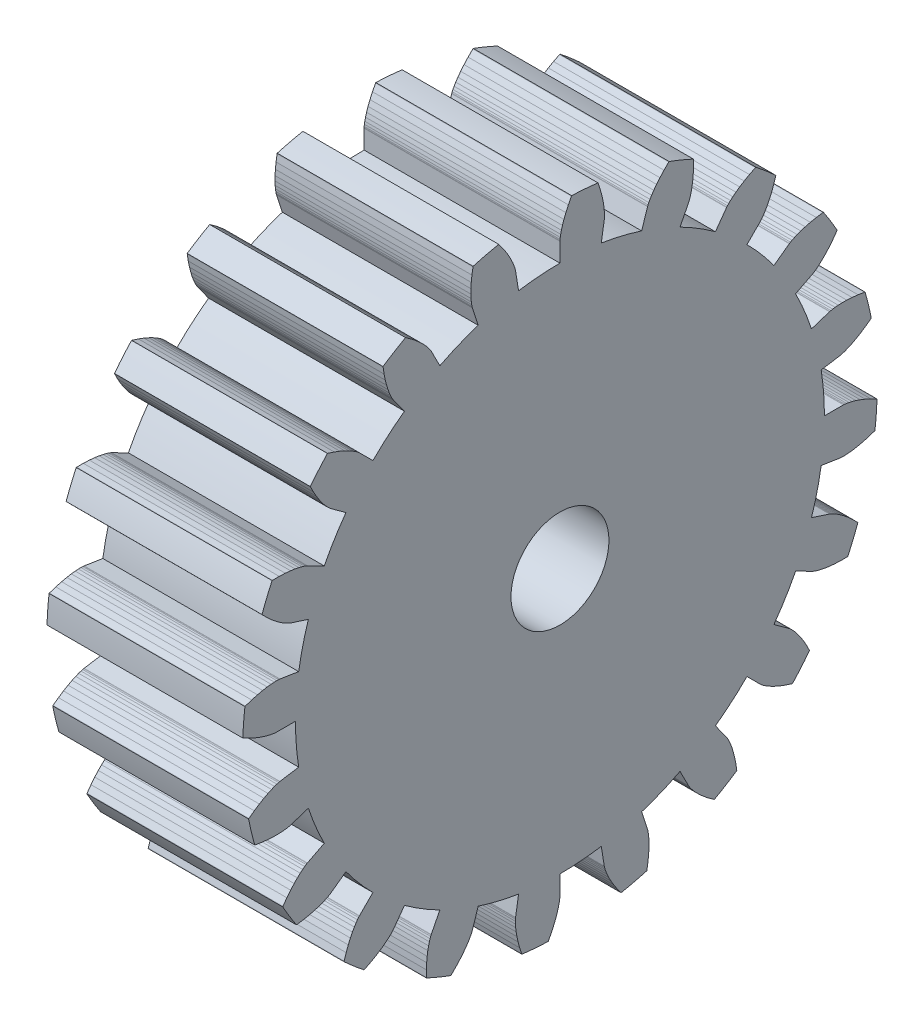
from build123d import *

# Parameters (mm, degrees)
BOSS_EXTRUDE1_DEPTH = 12.7
SKETCH2_R           = 3.175
CUT_EXTRUDE1_DEPTH  = 13.7


with BuildPart() as part:
    # Sketch1 → Boss-Extrude1 (new body)
    with BuildSketch(Plane(origin=(12.7, 0, 0), x_dir=(0, 0, -1), z_dir=(1, 0, 0))):
        with BuildLine():
            Line((2.682813922, 16.938620465), (2.875536908, 18.155425511))
            Line((2.875536908, 18.155425511), (2.87837281, 18.178225393))
            Line((2.87837281, 18.178225393), (2.883832937, 18.246933372))
            Line((2.883832937, 18.246933372), (2.887326064, 18.361754285))
            Line((2.887326064, 18.361754285), (2.884252784, 18.522548459))
            Line((2.884252784, 18.522548459), (2.870028474, 18.728831686))
            Line((2.870028474, 18.728831686), (2.840106238, 18.979776645))
            Line((2.840106238, 18.979776645), (2.789999721, 19.274215745))
            Line((2.789999721, 19.274215745), (2.715305726, 19.610645397))
            Line((2.715305726, 19.610645397), (2.611726539, 19.987231688))
            Line((2.611726539, 19.987231688), (2.475091875, 20.401817449))
            Line((2.475091875, 20.401817449), (2.46587773, 20.425692718))
            ThreePointArc((2.46587773, 20.425692718), (1.614217436, 20.510577224), (0.75976363, 20.55996681))
            Line((0.75976363, 20.55996681), (0.746928012, 20.537826895))
            Line((0.746928012, 20.537826895), (0.547120046, 20.149719743))
            Line((0.547120046, 20.149719743), (0.385905015, 19.793973209))
            Line((0.385905015, 19.793973209), (0.259501435, 19.47337028))
            Line((0.259501435, 19.47337028), (0.163951389, 19.190394599))
            Line((0.163951389, 19.190394599), (0.095141104, 18.947220058))
            Line((0.095141104, 18.947220058), (0.048822113, 18.745701692))
            Line((0.048822113, 18.745701692), (0.020632919, 18.587367929))
            Line((0.020632919, 18.587367929), (0.006121093, 18.473414206))
            Line((0.006121093, 18.473414206), (0.000765701, 18.404697984))
            Line((0.000765701, 18.404697984), (0, 18.381735174))
            Line((0, 18.381735174), (0, 17.1497625))
            ThreePointArc((0, 17.1497625), (-1.345554858, 17.096895506), (-2.682813922, 16.938620465))
            Line((-2.682813922, 16.938620465), (-2.875536908, 18.155425511))
            Line((-2.875536908, 18.155425511), (-2.879885357, 18.177985829))
            Line((-2.879885357, 18.177985829), (-2.895924401, 18.245018272))
            Line((-2.895924401, 18.245018272), (-2.928083852, 18.355298886))
            Line((-2.928083852, 18.355298886), (-2.980694848, 18.507273536))
            Line((-2.980694848, 18.507273536), (-3.057967993, 18.69906499))
            Line((-3.057967993, 18.69906499), (-3.163971988, 18.928481349))
            Line((-3.163971988, 18.928481349), (-3.302612804, 19.193025809))
            Line((-3.302612804, 19.193025809), (-3.477613494, 19.489907708))
            Line((-3.477613494, 19.489907708), (-3.692494719, 19.816054825))
            Line((-3.692494719, 19.816054825), (-3.950556052, 20.168126881))
            Line((-3.950556052, 20.168126881), (-3.966697089, 20.187986284))
            ThreePointArc((-3.966697089, 20.187986284), (-4.802904916, 20.005538742), (-5.630800996, 19.788470283))
            Line((-5.630800996, 19.788470283), (-5.636166785, 19.763447548))
            Line((-5.636166785, 19.763447548), (-5.706263748, 19.332591656))
            Line((-5.706263748, 19.332591656), (-5.749656629, 18.944438412))
            Line((-5.749656629, 18.944438412), (-5.770801824, 18.600466052))
            Line((-5.770801824, 18.600466052), (-5.774231023, 18.301813599))
            Line((-5.774231023, 18.301813599), (-5.764528427, 18.04927732))
            Line((-5.764528427, 18.04927732), (-5.746307806, 17.843308609))
            Line((-5.746307806, 17.843308609), (-5.724189498, 17.684013312))
            Line((-5.724189498, 17.684013312), (-5.702777429, 17.57115248))
            Line((-5.702777429, 17.57115248), (-5.686636229, 17.504144563))
            Line((-5.686636229, 17.504144563), (-5.680268555, 17.482069018))
            Line((-5.680268555, 17.482069018), (-5.299568062, 16.310393379))
            ThreePointArc((-5.299568062, 16.310393379), (-6.562929978, 15.844314561), (-7.785829248, 15.280550276))
            Line((-7.785829248, 15.280550276), (-8.345133138, 16.378245966))
            Line((-8.345133138, 16.378245966), (-8.35624028, 16.398358359))
            Line((-8.35624028, 16.398358359), (-8.392208481, 16.457153664))
            Line((-8.392208481, 16.457153664), (-8.456872521, 16.552098943))
            Line((-8.456872521, 16.552098943), (-8.553871301, 16.680377733))
            Line((-8.553871301, 16.680377733), (-8.686629248, 16.838903529))
            Line((-8.686629248, 16.838903529), (-8.858338591, 17.024334417))
            Line((-8.858338591, 17.024334417), (-9.071942576, 17.233088781))
            Line((-9.071942576, 17.233088781), (-9.330119675, 17.461362059))
            Line((-9.330119675, 17.461362059), (-9.635268866, 17.705144449))
            Line((-9.635268866, 17.705144449), (-9.989496027, 17.960239535))
            Line((-9.989496027, 17.960239535), (-10.010983958, 17.974139094))
            ThreePointArc((-10.010983958, 17.974139094), (-10.74988547, 17.542218741), (-11.47018359, 17.07994041))
            Line((-11.47018359, 17.07994041), (-11.467554308, 17.054484255))
            Line((-11.467554308, 17.054484255), (-11.401078688, 16.623054798))
            Line((-11.401078688, 16.623054798), (-11.322401821, 16.240489989))
            Line((-11.322401821, 16.240489989), (-11.236218792, 15.90681861))
            Line((-11.236218792, 15.90681861), (-11.147191471, 15.621723568))
            Line((-11.147191471, 15.621723568), (-11.059925752, 15.384545561))
            Line((-11.059925752, 15.384545561), (-10.978949079, 15.194288158))
            Line((-10.978949079, 15.194288158), (-10.908688365, 15.049624261))
            Line((-10.908688365, 15.049624261), (-10.853448362, 14.948903925))
            Line((-10.853448362, 14.948903925), (-10.817390583, 14.890163513))
            Line((-10.817390583, 14.890163513), (-10.804512847, 14.871136142))
            Line((-10.804512847, 14.871136142), (-10.080377478, 13.874449312))
            ThreePointArc((-10.080377478, 13.874449312), (-11.137879785, 13.040781714), (-12.126713359, 12.126713359))
            Line((-12.126713359, 12.126713359), (-12.997849592, 12.997849592))
            Line((-12.997849592, 12.997849592), (-13.014628182, 13.013545318))
            Line((-13.014628182, 13.013545318), (-13.067004723, 13.05834819))
            Line((-13.067004723, 13.05834819), (-13.157843584, 13.12866423))
            Line((-13.157843584, 13.12866423), (-13.289735232, 13.220690337))
            Line((-13.289735232, 13.220690337), (-13.464982708, 13.330432868))
            Line((-13.464982708, 13.330432868), (-13.685589294, 13.453727016))
            Line((-13.685589294, 13.453727016), (-13.953247401, 13.586256953))
            Line((-13.953247401, 13.586256953), (-14.269328736, 13.72357663))
            Line((-14.269328736, 13.72357663), (-14.634875764, 13.861131175))
            Line((-14.634875764, 13.861131175), (-15.05059453, 13.994278806))
            Line((-15.05059453, 13.994278806), (-15.075325967, 14.000857937))
            ThreePointArc((-15.075325967, 14.000857937), (-15.644592336, 13.361744146), (-16.186784696, 12.699506967))
            Line((-16.186784696, 12.699506967), (-16.176417716, 12.676109218))
            Line((-16.176417716, 12.676109218), (-15.97987661, 12.286337518))
            Line((-15.97987661, 12.286337518), (-15.786831436, 11.946809252))
            Line((-15.786831436, 11.946809252), (-15.601756378, 11.656100933))
            Line((-15.601756378, 11.656100933), (-15.428987151, 11.412470391))
            Line((-15.428987151, 11.412470391), (-15.272700485, 11.213867292))
            Line((-15.272700485, 11.213867292), (-15.136894322, 11.057944918))
            Line((-15.136894322, 11.057944918), (-15.025368809, 10.94207313))
            Line((-15.025368809, 10.94207313), (-14.941708149, 10.863352498))
            Line((-14.941708149, 10.863352498), (-14.889263378, 10.818629513))
            Line((-14.889263378, 10.818629513), (-14.871136142, 10.804512847))
            Line((-14.871136142, 10.804512847), (-13.874449312, 10.080377478))
            ThreePointArc((-13.874449312, 10.080377478), (-14.622576317, 8.960726291), (-15.280550276, 7.785829248))
            Line((-15.280550276, 7.785829248), (-16.378245966, 8.345133138))
            Line((-16.378245966, 8.345133138), (-16.3990536, 8.354875791))
            Line((-16.3990536, 8.354875791), (-16.462711499, 8.381300614))
            Line((-16.462711499, 8.381300614), (-16.570833241, 8.420104389))
            Line((-16.570833241, 8.420104389), (-16.724707284, 8.466869658))
            Line((-16.724707284, 8.466869658), (-16.925289844, 8.517086558))
            Line((-16.925289844, 8.517086558), (-17.173199163, 8.566175077))
            Line((-17.173199163, 8.566175077), (-17.468711153, 8.609507634))
            Line((-17.468711153, 8.609507634), (-17.81175648, 8.642431903))
            Line((-17.81175648, 8.642431903), (-18.201919055, 8.660293806))
            Line((-18.201919055, 8.660293806), (-18.638435977, 8.658460564))
            Line((-18.638435977, 8.658460564), (-18.663990035, 8.657075255))
            ThreePointArc((-18.663990035, 8.657075255), (-19.007897502, 7.873328937), (-19.318910536, 7.0759573))
            Line((-19.318910536, 7.0759573), (-19.30182065, 7.056908291))
            Line((-19.30182065, 7.056908291), (-18.994452871, 6.746947917))
            Line((-18.994452871, 6.746947917), (-18.705935996, 6.483691587))
            Line((-18.705935996, 6.483691587), (-18.440085345, 6.264402885))
            Line((-18.440085345, 6.264402885), (-18.200486068, 6.086085097))
            Line((-18.200486068, 6.086085097), (-17.990476884, 5.945497561))
            Line((-17.990476884, 5.945497561), (-17.813134884, 5.839172983))
            Line((-17.813134884, 5.839172983), (-17.671261467, 5.763435643))
            Line((-17.671261467, 5.763435643), (-17.567369437, 5.714420439))
            Line((-17.567369437, 5.714420439), (-17.503671334, 5.688092678))
            Line((-17.503671334, 5.688092678), (-17.482069018, 5.680268555))
            Line((-17.482069018, 5.680268555), (-16.310393379, 5.299568062))
            ThreePointArc((-16.310393379, 5.299568062), (-16.675913197, 4.003532547), (-16.938620465, 2.682813922))
            Line((-16.938620465, 2.682813922), (-18.155425511, 2.875536908))
            Line((-18.155425511, 2.875536908), (-18.178225393, 2.87837281))
            Line((-18.178225393, 2.87837281), (-18.246933372, 2.883832937))
            Line((-18.246933372, 2.883832937), (-18.361754285, 2.887326064))
            Line((-18.361754285, 2.887326064), (-18.522548459, 2.884252784))
            Line((-18.522548459, 2.884252784), (-18.728831686, 2.870028474))
            Line((-18.728831686, 2.870028474), (-18.979776645, 2.840106238))
            Line((-18.979776645, 2.840106238), (-19.274215745, 2.789999721))
            Line((-19.274215745, 2.789999721), (-19.610645397, 2.715305726))
            Line((-19.610645397, 2.715305726), (-19.987231688, 2.611726539))
            Line((-19.987231688, 2.611726539), (-20.401817449, 2.475091875))
            Line((-20.401817449, 2.475091875), (-20.425692718, 2.46587773))
            ThreePointArc((-20.425692718, 2.46587773), (-20.510577224, 1.614217436), (-20.55996681, 0.75976363))
            Line((-20.55996681, 0.75976363), (-20.537826895, 0.746928012))
            Line((-20.537826895, 0.746928012), (-20.149719743, 0.547120046))
            Line((-20.149719743, 0.547120046), (-19.793973209, 0.385905015))
            Line((-19.793973209, 0.385905015), (-19.47337028, 0.259501435))
            Line((-19.47337028, 0.259501435), (-19.190394599, 0.163951389))
            Line((-19.190394599, 0.163951389), (-18.947220058, 0.095141104))
            Line((-18.947220058, 0.095141104), (-18.745701692, 0.048822113))
            Line((-18.745701692, 0.048822113), (-18.587367929, 0.020632919))
            Line((-18.587367929, 0.020632919), (-18.473414206, 0.006121093))
            Line((-18.473414206, 0.006121093), (-18.404697984, 0.000765701))
            Line((-18.404697984, 0.000765701), (-18.381735174, 0))
            Line((-18.381735174, 0), (-17.1497625, 0))
            ThreePointArc((-17.1497625, 0), (-17.096895506, -1.345554858), (-16.938620465, -2.682813922))
            Line((-16.938620465, -2.682813922), (-18.155425511, -2.875536908))
            Line((-18.155425511, -2.875536908), (-18.177985829, -2.879885357))
            Line((-18.177985829, -2.879885357), (-18.245018272, -2.895924401))
            Line((-18.245018272, -2.895924401), (-18.355298886, -2.928083852))
            Line((-18.355298886, -2.928083852), (-18.507273536, -2.980694848))
            Line((-18.507273536, -2.980694848), (-18.69906499, -3.057967993))
            Line((-18.69906499, -3.057967993), (-18.928481349, -3.163971988))
            Line((-18.928481349, -3.163971988), (-19.193025809, -3.302612804))
            Line((-19.193025809, -3.302612804), (-19.489907708, -3.477613494))
            Line((-19.489907708, -3.477613494), (-19.816054825, -3.692494719))
            Line((-19.816054825, -3.692494719), (-20.168126881, -3.950556052))
            Line((-20.168126881, -3.950556052), (-20.187986284, -3.966697089))
            ThreePointArc((-20.187986284, -3.966697089), (-20.005538742, -4.802904916), (-19.788470283, -5.630800996))
            Line((-19.788470283, -5.630800996), (-19.763447548, -5.636166785))
            Line((-19.763447548, -5.636166785), (-19.332591656, -5.706263748))
            Line((-19.332591656, -5.706263748), (-18.944438412, -5.749656629))
            Line((-18.944438412, -5.749656629), (-18.600466052, -5.770801824))
            Line((-18.600466052, -5.770801824), (-18.301813599, -5.774231023))
            Line((-18.301813599, -5.774231023), (-18.04927732, -5.764528427))
            Line((-18.04927732, -5.764528427), (-17.843308609, -5.746307806))
            Line((-17.843308609, -5.746307806), (-17.684013312, -5.724189498))
            Line((-17.684013312, -5.724189498), (-17.57115248, -5.702777429))
            Line((-17.57115248, -5.702777429), (-17.504144563, -5.686636229))
            Line((-17.504144563, -5.686636229), (-17.482069018, -5.680268555))
            Line((-17.482069018, -5.680268555), (-16.310393379, -5.299568062))
            ThreePointArc((-16.310393379, -5.299568062), (-15.844314561, -6.562929978), (-15.280550276, -7.785829248))
            Line((-15.280550276, -7.785829248), (-16.378245966, -8.345133138))
            Line((-16.378245966, -8.345133138), (-16.398358359, -8.35624028))
            Line((-16.398358359, -8.35624028), (-16.457153664, -8.392208481))
            Line((-16.457153664, -8.392208481), (-16.552098943, -8.456872521))
            Line((-16.552098943, -8.456872521), (-16.680377733, -8.553871301))
            Line((-16.680377733, -8.553871301), (-16.838903529, -8.686629248))
            Line((-16.838903529, -8.686629248), (-17.024334417, -8.858338591))
            Line((-17.024334417, -8.858338591), (-17.233088781, -9.071942576))
            Line((-17.233088781, -9.071942576), (-17.461362059, -9.330119675))
            Line((-17.461362059, -9.330119675), (-17.705144449, -9.635268866))
            Line((-17.705144449, -9.635268866), (-17.960239535, -9.989496027))
            Line((-17.960239535, -9.989496027), (-17.974139094, -10.010983958))
            ThreePointArc((-17.974139094, -10.010983958), (-17.542218741, -10.74988547), (-17.07994041, -11.47018359))
            Line((-17.07994041, -11.47018359), (-17.054484255, -11.467554308))
            Line((-17.054484255, -11.467554308), (-16.623054798, -11.401078688))
            Line((-16.623054798, -11.401078688), (-16.240489989, -11.322401821))
            Line((-16.240489989, -11.322401821), (-15.90681861, -11.236218792))
            Line((-15.90681861, -11.236218792), (-15.621723568, -11.147191471))
            Line((-15.621723568, -11.147191471), (-15.384545561, -11.059925752))
            Line((-15.384545561, -11.059925752), (-15.194288158, -10.978949079))
            Line((-15.194288158, -10.978949079), (-15.049624261, -10.908688365))
            Line((-15.049624261, -10.908688365), (-14.948903925, -10.853448362))
            Line((-14.948903925, -10.853448362), (-14.890163513, -10.817390583))
            Line((-14.890163513, -10.817390583), (-14.871136142, -10.804512847))
            Line((-14.871136142, -10.804512847), (-13.874449312, -10.080377478))
            ThreePointArc((-13.874449312, -10.080377478), (-13.040781714, -11.137879785), (-12.126713359, -12.126713359))
            Line((-12.126713359, -12.126713359), (-12.997849592, -12.997849592))
            Line((-12.997849592, -12.997849592), (-13.013545318, -13.014628182))
            Line((-13.013545318, -13.014628182), (-13.05834819, -13.067004723))
            Line((-13.05834819, -13.067004723), (-13.12866423, -13.157843584))
            Line((-13.12866423, -13.157843584), (-13.220690337, -13.289735232))
            Line((-13.220690337, -13.289735232), (-13.330432868, -13.464982708))
            Line((-13.330432868, -13.464982708), (-13.453727016, -13.685589294))
            Line((-13.453727016, -13.685589294), (-13.586256953, -13.953247401))
            Line((-13.586256953, -13.953247401), (-13.72357663, -14.269328736))
            Line((-13.72357663, -14.269328736), (-13.861131175, -14.634875764))
            Line((-13.861131175, -14.634875764), (-13.994278806, -15.05059453))
            Line((-13.994278806, -15.05059453), (-14.000857937, -15.075325967))
            ThreePointArc((-14.000857937, -15.075325967), (-13.361744146, -15.644592336), (-12.699506967, -16.186784696))
            Line((-12.699506967, -16.186784696), (-12.676109218, -16.176417716))
            Line((-12.676109218, -16.176417716), (-12.286337518, -15.97987661))
            Line((-12.286337518, -15.97987661), (-11.946809252, -15.786831436))
            Line((-11.946809252, -15.786831436), (-11.656100933, -15.601756378))
            Line((-11.656100933, -15.601756378), (-11.412470391, -15.428987151))
            Line((-11.412470391, -15.428987151), (-11.213867292, -15.272700485))
            Line((-11.213867292, -15.272700485), (-11.057944918, -15.136894322))
            Line((-11.057944918, -15.136894322), (-10.94207313, -15.025368809))
            Line((-10.94207313, -15.025368809), (-10.863352498, -14.941708149))
            Line((-10.863352498, -14.941708149), (-10.818629513, -14.889263378))
            Line((-10.818629513, -14.889263378), (-10.804512847, -14.871136142))
            Line((-10.804512847, -14.871136142), (-10.080377478, -13.874449312))
            ThreePointArc((-10.080377478, -13.874449312), (-8.960726291, -14.622576317), (-7.785829248, -15.280550276))
            Line((-7.785829248, -15.280550276), (-8.345133138, -16.378245966))
            Line((-8.345133138, -16.378245966), (-8.354875791, -16.3990536))
            Line((-8.354875791, -16.3990536), (-8.381300614, -16.462711499))
            Line((-8.381300614, -16.462711499), (-8.420104389, -16.570833241))
            Line((-8.420104389, -16.570833241), (-8.466869658, -16.724707284))
            Line((-8.466869658, -16.724707284), (-8.517086558, -16.925289844))
            Line((-8.517086558, -16.925289844), (-8.566175077, -17.173199163))
            Line((-8.566175077, -17.173199163), (-8.609507634, -17.468711153))
            Line((-8.609507634, -17.468711153), (-8.642431903, -17.81175648))
            Line((-8.642431903, -17.81175648), (-8.660293806, -18.201919055))
            Line((-8.660293806, -18.201919055), (-8.658460564, -18.638435977))
            Line((-8.658460564, -18.638435977), (-8.657075255, -18.663990035))
            ThreePointArc((-8.657075255, -18.663990035), (-7.873328937, -19.007897502), (-7.0759573, -19.318910536))
            Line((-7.0759573, -19.318910536), (-7.056908291, -19.30182065))
            Line((-7.056908291, -19.30182065), (-6.746947917, -18.994452871))
            Line((-6.746947917, -18.994452871), (-6.483691587, -18.705935996))
            Line((-6.483691587, -18.705935996), (-6.264402885, -18.440085345))
            Line((-6.264402885, -18.440085345), (-6.086085097, -18.200486068))
            Line((-6.086085097, -18.200486068), (-5.945497561, -17.990476884))
            Line((-5.945497561, -17.990476884), (-5.839172983, -17.813134884))
            Line((-5.839172983, -17.813134884), (-5.763435643, -17.671261467))
            Line((-5.763435643, -17.671261467), (-5.714420439, -17.567369437))
            Line((-5.714420439, -17.567369437), (-5.688092678, -17.503671334))
            Line((-5.688092678, -17.503671334), (-5.680268555, -17.482069018))
            Line((-5.680268555, -17.482069018), (-5.299568062, -16.310393379))
            ThreePointArc((-5.299568062, -16.310393379), (-4.003532547, -16.675913197), (-2.682813922, -16.938620465))
            Line((-2.682813922, -16.938620465), (-2.875536908, -18.155425511))
            Line((-2.875536908, -18.155425511), (-2.87837281, -18.178225393))
            Line((-2.87837281, -18.178225393), (-2.883832937, -18.246933372))
            Line((-2.883832937, -18.246933372), (-2.887326064, -18.361754285))
            Line((-2.887326064, -18.361754285), (-2.884252784, -18.522548459))
            Line((-2.884252784, -18.522548459), (-2.870028474, -18.728831686))
            Line((-2.870028474, -18.728831686), (-2.840106238, -18.979776645))
            Line((-2.840106238, -18.979776645), (-2.789999721, -19.274215745))
            Line((-2.789999721, -19.274215745), (-2.715305726, -19.610645397))
            Line((-2.715305726, -19.610645397), (-2.611726539, -19.987231688))
            Line((-2.611726539, -19.987231688), (-2.475091875, -20.401817449))
            Line((-2.475091875, -20.401817449), (-2.46587773, -20.425692718))
            ThreePointArc((-2.46587773, -20.425692718), (-1.614217436, -20.510577224), (-0.75976363, -20.55996681))
            Line((-0.75976363, -20.55996681), (-0.746928012, -20.537826895))
            Line((-0.746928012, -20.537826895), (-0.547120046, -20.149719743))
            Line((-0.547120046, -20.149719743), (-0.385905015, -19.793973209))
            Line((-0.385905015, -19.793973209), (-0.259501435, -19.47337028))
            Line((-0.259501435, -19.47337028), (-0.163951389, -19.190394599))
            Line((-0.163951389, -19.190394599), (-0.095141104, -18.947220058))
            Line((-0.095141104, -18.947220058), (-0.048822113, -18.745701692))
            Line((-0.048822113, -18.745701692), (-0.020632919, -18.587367929))
            Line((-0.020632919, -18.587367929), (-0.006121093, -18.473414206))
            Line((-0.006121093, -18.473414206), (-0.000765701, -18.404697984))
            Line((-0.000765701, -18.404697984), (0, -18.381735174))
            Line((0, -18.381735174), (0, -17.1497625))
            ThreePointArc((0, -17.1497625), (1.345554858, -17.096895506), (2.682813922, -16.938620465))
            Line((2.682813922, -16.938620465), (2.875536908, -18.155425511))
            Line((2.875536908, -18.155425511), (2.879885357, -18.177985829))
            Line((2.879885357, -18.177985829), (2.895924401, -18.245018272))
            Line((2.895924401, -18.245018272), (2.928083852, -18.355298886))
            Line((2.928083852, -18.355298886), (2.980694848, -18.507273536))
            Line((2.980694848, -18.507273536), (3.057967993, -18.69906499))
            Line((3.057967993, -18.69906499), (3.163971988, -18.928481349))
            Line((3.163971988, -18.928481349), (3.302612804, -19.193025809))
            Line((3.302612804, -19.193025809), (3.477613494, -19.489907708))
            Line((3.477613494, -19.489907708), (3.692494719, -19.816054825))
            Line((3.692494719, -19.816054825), (3.950556052, -20.168126881))
            Line((3.950556052, -20.168126881), (3.966697089, -20.187986284))
            ThreePointArc((3.966697089, -20.187986284), (4.802904916, -20.005538742), (5.630800996, -19.788470283))
            Line((5.630800996, -19.788470283), (5.636166785, -19.763447548))
            Line((5.636166785, -19.763447548), (5.706263748, -19.332591656))
            Line((5.706263748, -19.332591656), (5.749656629, -18.944438412))
            Line((5.749656629, -18.944438412), (5.770801824, -18.600466052))
            Line((5.770801824, -18.600466052), (5.774231023, -18.301813599))
            Line((5.774231023, -18.301813599), (5.764528427, -18.04927732))
            Line((5.764528427, -18.04927732), (5.746307806, -17.843308609))
            Line((5.746307806, -17.843308609), (5.724189498, -17.684013312))
            Line((5.724189498, -17.684013312), (5.702777429, -17.57115248))
            Line((5.702777429, -17.57115248), (5.686636229, -17.504144563))
            Line((5.686636229, -17.504144563), (5.680268555, -17.482069018))
            Line((5.680268555, -17.482069018), (5.299568062, -16.310393379))
            ThreePointArc((5.299568062, -16.310393379), (6.562929978, -15.844314561), (7.785829248, -15.280550276))
            Line((7.785829248, -15.280550276), (8.345133138, -16.378245966))
            Line((8.345133138, -16.378245966), (8.35624028, -16.398358359))
            Line((8.35624028, -16.398358359), (8.392208481, -16.457153664))
            Line((8.392208481, -16.457153664), (8.456872521, -16.552098943))
            Line((8.456872521, -16.552098943), (8.553871301, -16.680377733))
            Line((8.553871301, -16.680377733), (8.686629248, -16.838903529))
            Line((8.686629248, -16.838903529), (8.858338591, -17.024334417))
            Line((8.858338591, -17.024334417), (9.071942576, -17.233088781))
            Line((9.071942576, -17.233088781), (9.330119675, -17.461362059))
            Line((9.330119675, -17.461362059), (9.635268866, -17.705144449))
            Line((9.635268866, -17.705144449), (9.989496027, -17.960239535))
            Line((9.989496027, -17.960239535), (10.010983958, -17.974139094))
            ThreePointArc((10.010983958, -17.974139094), (10.74988547, -17.542218741), (11.47018359, -17.07994041))
            Line((11.47018359, -17.07994041), (11.467554308, -17.054484255))
            Line((11.467554308, -17.054484255), (11.401078688, -16.623054798))
            Line((11.401078688, -16.623054798), (11.322401821, -16.240489989))
            Line((11.322401821, -16.240489989), (11.236218792, -15.90681861))
            Line((11.236218792, -15.90681861), (11.147191471, -15.621723568))
            Line((11.147191471, -15.621723568), (11.059925752, -15.384545561))
            Line((11.059925752, -15.384545561), (10.978949079, -15.194288158))
            Line((10.978949079, -15.194288158), (10.908688365, -15.049624261))
            Line((10.908688365, -15.049624261), (10.853448362, -14.948903925))
            Line((10.853448362, -14.948903925), (10.817390583, -14.890163513))
            Line((10.817390583, -14.890163513), (10.804512847, -14.871136142))
            Line((10.804512847, -14.871136142), (10.080377478, -13.874449312))
            ThreePointArc((10.080377478, -13.874449312), (11.137879785, -13.040781714), (12.126713359, -12.126713359))
            Line((12.126713359, -12.126713359), (12.997849592, -12.997849592))
            Line((12.997849592, -12.997849592), (13.014628182, -13.013545318))
            Line((13.014628182, -13.013545318), (13.067004723, -13.05834819))
            Line((13.067004723, -13.05834819), (13.157843584, -13.12866423))
            Line((13.157843584, -13.12866423), (13.289735232, -13.220690337))
            Line((13.289735232, -13.220690337), (13.464982708, -13.330432868))
            Line((13.464982708, -13.330432868), (13.685589294, -13.453727016))
            Line((13.685589294, -13.453727016), (13.953247401, -13.586256953))
            Line((13.953247401, -13.586256953), (14.269328736, -13.72357663))
            Line((14.269328736, -13.72357663), (14.634875764, -13.861131175))
            Line((14.634875764, -13.861131175), (15.05059453, -13.994278806))
            Line((15.05059453, -13.994278806), (15.075325967, -14.000857937))
            ThreePointArc((15.075325967, -14.000857937), (15.644592336, -13.361744146), (16.186784696, -12.699506967))
            Line((16.186784696, -12.699506967), (16.176417716, -12.676109218))
            Line((16.176417716, -12.676109218), (15.97987661, -12.286337518))
            Line((15.97987661, -12.286337518), (15.786831436, -11.946809252))
            Line((15.786831436, -11.946809252), (15.601756378, -11.656100933))
            Line((15.601756378, -11.656100933), (15.428987151, -11.412470391))
            Line((15.428987151, -11.412470391), (15.272700485, -11.213867292))
            Line((15.272700485, -11.213867292), (15.136894322, -11.057944918))
            Line((15.136894322, -11.057944918), (15.025368809, -10.94207313))
            Line((15.025368809, -10.94207313), (14.941708149, -10.863352498))
            Line((14.941708149, -10.863352498), (14.889263378, -10.818629513))
            Line((14.889263378, -10.818629513), (14.871136142, -10.804512847))
            Line((14.871136142, -10.804512847), (13.874449312, -10.080377478))
            ThreePointArc((13.874449312, -10.080377478), (14.622576317, -8.960726291), (15.280550276, -7.785829248))
            Line((15.280550276, -7.785829248), (16.378245966, -8.345133138))
            Line((16.378245966, -8.345133138), (16.3990536, -8.354875791))
            Line((16.3990536, -8.354875791), (16.462711499, -8.381300614))
            Line((16.462711499, -8.381300614), (16.570833241, -8.420104389))
            Line((16.570833241, -8.420104389), (16.724707284, -8.466869658))
            Line((16.724707284, -8.466869658), (16.925289844, -8.517086558))
            Line((16.925289844, -8.517086558), (17.173199163, -8.566175077))
            Line((17.173199163, -8.566175077), (17.468711153, -8.609507634))
            Line((17.468711153, -8.609507634), (17.81175648, -8.642431903))
            Line((17.81175648, -8.642431903), (18.201919055, -8.660293806))
            Line((18.201919055, -8.660293806), (18.638435977, -8.658460564))
            Line((18.638435977, -8.658460564), (18.663990035, -8.657075255))
            ThreePointArc((18.663990035, -8.657075255), (19.007897502, -7.873328937), (19.318910536, -7.0759573))
            Line((19.318910536, -7.0759573), (19.30182065, -7.056908291))
            Line((19.30182065, -7.056908291), (18.994452871, -6.746947917))
            Line((18.994452871, -6.746947917), (18.705935996, -6.483691587))
            Line((18.705935996, -6.483691587), (18.440085345, -6.264402885))
            Line((18.440085345, -6.264402885), (18.200486068, -6.086085097))
            Line((18.200486068, -6.086085097), (17.990476884, -5.945497561))
            Line((17.990476884, -5.945497561), (17.813134884, -5.839172983))
            Line((17.813134884, -5.839172983), (17.671261467, -5.763435643))
            Line((17.671261467, -5.763435643), (17.567369437, -5.714420439))
            Line((17.567369437, -5.714420439), (17.503671334, -5.688092678))
            Line((17.503671334, -5.688092678), (17.482069018, -5.680268555))
            Line((17.482069018, -5.680268555), (16.310393379, -5.299568062))
            ThreePointArc((16.310393379, -5.299568062), (16.675913197, -4.003532547), (16.938620465, -2.682813922))
            Line((16.938620465, -2.682813922), (18.155425511, -2.875536908))
            Line((18.155425511, -2.875536908), (18.178225393, -2.87837281))
            Line((18.178225393, -2.87837281), (18.246933372, -2.883832937))
            Line((18.246933372, -2.883832937), (18.361754285, -2.887326064))
            Line((18.361754285, -2.887326064), (18.522548459, -2.884252784))
            Line((18.522548459, -2.884252784), (18.728831686, -2.870028474))
            Line((18.728831686, -2.870028474), (18.979776645, -2.840106238))
            Line((18.979776645, -2.840106238), (19.274215745, -2.789999721))
            Line((19.274215745, -2.789999721), (19.610645397, -2.715305726))
            Line((19.610645397, -2.715305726), (19.987231688, -2.611726539))
            Line((19.987231688, -2.611726539), (20.401817449, -2.475091875))
            Line((20.401817449, -2.475091875), (20.425692718, -2.46587773))
            ThreePointArc((20.425692718, -2.46587773), (20.510577224, -1.614217436), (20.55996681, -0.75976363))
            Line((20.55996681, -0.75976363), (20.537826895, -0.746928012))
            Line((20.537826895, -0.746928012), (20.149719743, -0.547120046))
            Line((20.149719743, -0.547120046), (19.793973209, -0.385905015))
            Line((19.793973209, -0.385905015), (19.47337028, -0.259501435))
            Line((19.47337028, -0.259501435), (19.190394599, -0.163951389))
            Line((19.190394599, -0.163951389), (18.947220058, -0.095141104))
            Line((18.947220058, -0.095141104), (18.745701692, -0.048822113))
            Line((18.745701692, -0.048822113), (18.587367929, -0.020632919))
            Line((18.587367929, -0.020632919), (18.473414206, -0.006121093))
            Line((18.473414206, -0.006121093), (18.404697984, -0.000765701))
            Line((18.404697984, -0.000765701), (18.381735174, 0))
            Line((18.381735174, 0), (17.1497625, 0))
            ThreePointArc((17.1497625, 0), (17.096895506, 1.345554858), (16.938620465, 2.682813922))
            Line((16.938620465, 2.682813922), (18.155425511, 2.875536908))
            Line((18.155425511, 2.875536908), (18.177985829, 2.879885357))
            Line((18.177985829, 2.879885357), (18.245018272, 2.895924401))
            Line((18.245018272, 2.895924401), (18.355298886, 2.928083852))
            Line((18.355298886, 2.928083852), (18.507273536, 2.980694848))
            Line((18.507273536, 2.980694848), (18.69906499, 3.057967993))
            Line((18.69906499, 3.057967993), (18.928481349, 3.163971988))
            Line((18.928481349, 3.163971988), (19.193025809, 3.302612804))
            Line((19.193025809, 3.302612804), (19.489907708, 3.477613494))
            Line((19.489907708, 3.477613494), (19.816054825, 3.692494719))
            Line((19.816054825, 3.692494719), (20.168126881, 3.950556052))
            Line((20.168126881, 3.950556052), (20.187986284, 3.966697089))
            ThreePointArc((20.187986284, 3.966697089), (20.005538742, 4.802904916), (19.788470283, 5.630800996))
            Line((19.788470283, 5.630800996), (19.763447548, 5.636166785))
            Line((19.763447548, 5.636166785), (19.332591656, 5.706263748))
            Line((19.332591656, 5.706263748), (18.944438412, 5.749656629))
            Line((18.944438412, 5.749656629), (18.600466052, 5.770801824))
            Line((18.600466052, 5.770801824), (18.301813599, 5.774231023))
            Line((18.301813599, 5.774231023), (18.04927732, 5.764528427))
            Line((18.04927732, 5.764528427), (17.843308609, 5.746307806))
            Line((17.843308609, 5.746307806), (17.684013312, 5.724189498))
            Line((17.684013312, 5.724189498), (17.57115248, 5.702777429))
            Line((17.57115248, 5.702777429), (17.504144563, 5.686636229))
            Line((17.504144563, 5.686636229), (17.482069018, 5.680268555))
            Line((17.482069018, 5.680268555), (16.310393379, 5.299568062))
            ThreePointArc((16.310393379, 5.299568062), (15.844314561, 6.562929978), (15.280550276, 7.785829248))
            Line((15.280550276, 7.785829248), (16.378245966, 8.345133138))
            Line((16.378245966, 8.345133138), (16.398358359, 8.35624028))
            Line((16.398358359, 8.35624028), (16.457153664, 8.392208481))
            Line((16.457153664, 8.392208481), (16.552098943, 8.456872521))
            Line((16.552098943, 8.456872521), (16.680377733, 8.553871301))
            Line((16.680377733, 8.553871301), (16.838903529, 8.686629248))
            Line((16.838903529, 8.686629248), (17.024334417, 8.858338591))
            Line((17.024334417, 8.858338591), (17.233088781, 9.071942576))
            Line((17.233088781, 9.071942576), (17.461362059, 9.330119675))
            Line((17.461362059, 9.330119675), (17.705144449, 9.635268866))
            Line((17.705144449, 9.635268866), (17.960239535, 9.989496027))
            Line((17.960239535, 9.989496027), (17.974139094, 10.010983958))
            ThreePointArc((17.974139094, 10.010983958), (17.542218741, 10.74988547), (17.07994041, 11.47018359))
            Line((17.07994041, 11.47018359), (17.054484255, 11.467554308))
            Line((17.054484255, 11.467554308), (16.623054798, 11.401078688))
            Line((16.623054798, 11.401078688), (16.240489989, 11.322401821))
            Line((16.240489989, 11.322401821), (15.90681861, 11.236218792))
            Line((15.90681861, 11.236218792), (15.621723568, 11.147191471))
            Line((15.621723568, 11.147191471), (15.384545561, 11.059925752))
            Line((15.384545561, 11.059925752), (15.194288158, 10.978949079))
            Line((15.194288158, 10.978949079), (15.049624261, 10.908688365))
            Line((15.049624261, 10.908688365), (14.948903925, 10.853448362))
            Line((14.948903925, 10.853448362), (14.890163513, 10.817390583))
            Line((14.890163513, 10.817390583), (14.871136142, 10.804512847))
            Line((14.871136142, 10.804512847), (13.874449312, 10.080377478))
            ThreePointArc((13.874449312, 10.080377478), (13.040781714, 11.137879785), (12.126713359, 12.126713359))
            Line((12.126713359, 12.126713359), (12.997849592, 12.997849592))
            Line((12.997849592, 12.997849592), (13.013545318, 13.014628182))
            Line((13.013545318, 13.014628182), (13.05834819, 13.067004723))
            Line((13.05834819, 13.067004723), (13.12866423, 13.157843584))
            Line((13.12866423, 13.157843584), (13.220690337, 13.289735232))
            Line((13.220690337, 13.289735232), (13.330432868, 13.464982708))
            Line((13.330432868, 13.464982708), (13.453727016, 13.685589294))
            Line((13.453727016, 13.685589294), (13.586256953, 13.953247401))
            Line((13.586256953, 13.953247401), (13.72357663, 14.269328736))
            Line((13.72357663, 14.269328736), (13.861131175, 14.634875764))
            Line((13.861131175, 14.634875764), (13.994278806, 15.05059453))
            Line((13.994278806, 15.05059453), (14.000857937, 15.075325967))
            ThreePointArc((14.000857937, 15.075325967), (13.361744146, 15.644592336), (12.699506967, 16.186784696))
            Line((12.699506967, 16.186784696), (12.676109218, 16.176417716))
            Line((12.676109218, 16.176417716), (12.286337518, 15.97987661))
            Line((12.286337518, 15.97987661), (11.946809252, 15.786831436))
            Line((11.946809252, 15.786831436), (11.656100933, 15.601756378))
            Line((11.656100933, 15.601756378), (11.412470391, 15.428987151))
            Line((11.412470391, 15.428987151), (11.213867292, 15.272700485))
            Line((11.213867292, 15.272700485), (11.057944918, 15.136894322))
            Line((11.057944918, 15.136894322), (10.94207313, 15.025368809))
            Line((10.94207313, 15.025368809), (10.863352498, 14.941708149))
            Line((10.863352498, 14.941708149), (10.818629513, 14.889263378))
            Line((10.818629513, 14.889263378), (10.804512847, 14.871136142))
            Line((10.804512847, 14.871136142), (10.080377478, 13.874449312))
            ThreePointArc((10.080377478, 13.874449312), (8.960726291, 14.622576317), (7.785829248, 15.280550276))
            Line((7.785829248, 15.280550276), (8.345133138, 16.378245966))
            Line((8.345133138, 16.378245966), (8.354875791, 16.3990536))
            Line((8.354875791, 16.3990536), (8.381300614, 16.462711499))
            Line((8.381300614, 16.462711499), (8.420104389, 16.570833241))
            Line((8.420104389, 16.570833241), (8.466869658, 16.724707284))
            Line((8.466869658, 16.724707284), (8.517086558, 16.925289844))
            Line((8.517086558, 16.925289844), (8.566175077, 17.173199163))
            Line((8.566175077, 17.173199163), (8.609507634, 17.468711153))
            Line((8.609507634, 17.468711153), (8.642431903, 17.81175648))
            Line((8.642431903, 17.81175648), (8.660293806, 18.201919055))
            Line((8.660293806, 18.201919055), (8.658460564, 18.638435977))
            Line((8.658460564, 18.638435977), (8.657075255, 18.663990035))
            ThreePointArc((8.657075255, 18.663990035), (7.873328937, 19.007897502), (7.0759573, 19.318910536))
            Line((7.0759573, 19.318910536), (7.056908291, 19.30182065))
            Line((7.056908291, 19.30182065), (6.746947917, 18.994452871))
            Line((6.746947917, 18.994452871), (6.483691587, 18.705935996))
            Line((6.483691587, 18.705935996), (6.264402885, 18.440085345))
            Line((6.264402885, 18.440085345), (6.086085097, 18.200486068))
            Line((6.086085097, 18.200486068), (5.945497561, 17.990476884))
            Line((5.945497561, 17.990476884), (5.839172983, 17.813134884))
            Line((5.839172983, 17.813134884), (5.763435643, 17.671261467))
            Line((5.763435643, 17.671261467), (5.714420439, 17.567369437))
            Line((5.714420439, 17.567369437), (5.688092678, 17.503671334))
            Line((5.688092678, 17.503671334), (5.680268555, 17.482069018))
            Line((5.680268555, 17.482069018), (5.299568062, 16.310393379))
            ThreePointArc((5.299568062, 16.310393379), (4.003532547, 16.675913197), (2.682813922, 16.938620465))
        make_face()
    extrude(amount=-BOSS_EXTRUDE1_DEPTH)

    # Sketch2 → Cut-Extrude1 (cut, through all)
    with BuildSketch(Plane.ZY):
        Circle(SKETCH2_R)
    extrude(amount=-CUT_EXTRUDE1_DEPTH, mode=Mode.SUBTRACT)


solid = part.part
